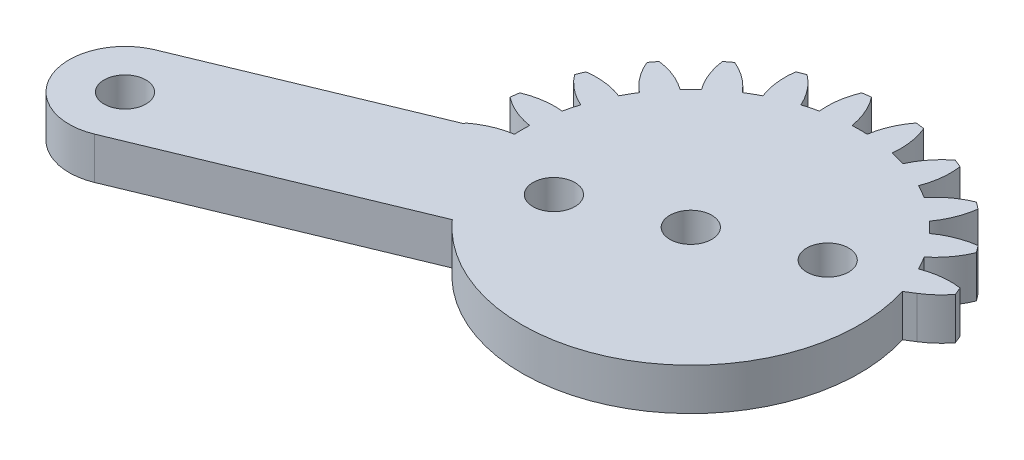
from build123d import *

# Parameters (mm, degrees)
SKETCH1_R           = 1.5
BOSS_EXTRUDE1_DEPTH = 3


with BuildPart() as part:
    # Sketch1 → Boss-Extrude1 (new body)
    with BuildSketch(Plane(origin=(0, 0, 0), x_dir=(1, 0, 0), z_dir=(0, 1, 0))):
        with BuildLine():
            Line((-9.012614242, -8.062715867), (-27.10951678, -15.558698335))
            ThreePointArc((-27.10951678, -15.558698335), (-32.335768639, -13.393913934), (-30.170984238, -8.167662075))
            Line((-30.170984238, -8.167662075), (-14.527279952, -1.687827594))
            ThreePointArc((-14.527279952, -1.687827594), (-14.532365143, -1.643468323), (-14.537314884, -1.599093734))
            ThreePointArc((-14.537314884, -1.599093734), (-13.375367561, -0.916420891), (-12.08056518, -0.542722374))
            ThreePointArc((-12.08056518, -0.542722374), (-12.092750003, -1.6e-08), (-12.080565181, 0.542722343))
            ThreePointArc((-12.080565181, 0.542722343), (-13.375367564, 0.91642086), (-14.537314887, 1.599093703))
            ThreePointArc((-14.537314887, 1.599093703), (-14.499881093, 1.908945545), (-14.455843804, 2.217928021))
            ThreePointArc((-14.455843804, 2.217928021), (-13.156800144, 2.576605254), (-11.80939679, 2.602450787))
            ThreePointArc((-11.80939679, 2.602450787), (-11.680699543, 3.129833994), (-11.528463026, 3.650909874))
            ThreePointArc((-11.528463026, 3.650909874), (-12.682425794, 4.346994439), (-13.628091988, 5.307139865))
            ThreePointArc((-13.628091988, 5.307139865), (-13.511738162, 5.596745183), (-13.389230858, 5.883801647))
            ThreePointArc((-13.389230858, 5.883801647), (-12.041618538, 5.89404001), (-10.733437524, 5.570271228))
            ThreePointArc((-10.733437524, 5.570271228), (-10.472628711, 6.046374991), (-10.190715165, 6.51029393))
            ThreePointArc((-10.190715165, 6.51029393), (-11.125197663, 7.48132753), (-11.790137141, 8.653513216))
            ThreePointArc((-11.790137141, 8.653513216), (-11.602792603, 8.903135886), (-11.410163954, 9.148703915))
            ThreePointArc((-11.410163954, 9.148703915), (-10.105820527, 8.80980568), (-8.926012227, 8.158486891))
            ThreePointArc((-8.926012227, 8.158486891), (-8.550865537, 8.550865523), (-8.158486906, 8.926012214))
            ThreePointArc((-8.158486906, 8.926012214), (-8.809805695, 10.105820514), (-9.148703931, 11.410163942))
            ThreePointArc((-9.148703931, 11.410163942), (-8.903135901, 11.602792591), (-8.653513232, 11.79013713))
            ThreePointArc((-8.653513232, 11.79013713), (-7.481327547, 11.125197652), (-6.510293947, 10.190715155))
            ThreePointArc((-6.510293947, 10.190715155), (-6.046375007, 10.472628701), (-5.570271245, 10.733437515))
            ThreePointArc((-5.570271245, 10.733437515), (-5.894040027, 12.04161853), (-5.883801664, 13.38923085))
            ThreePointArc((-5.883801664, 13.38923085), (-5.5967452, 13.511738155), (-5.307139882, 13.628091982))
            ThreePointArc((-5.307139882, 13.628091982), (-4.346994456, 12.682425788), (-3.650909891, 11.52846302))
            ThreePointArc((-3.650909891, 11.52846302), (-3.129834011, 11.680699538), (-2.602450802, 11.809396786))
            ThreePointArc((-2.602450802, 11.809396786), (-2.57660527, 13.156800141), (-2.217928037, 14.455843802))
            ThreePointArc((-2.217928037, 14.455843802), (-1.908945561, 14.499881091), (-1.599093718, 14.537314885))
            ThreePointArc((-1.599093718, 14.537314885), (-0.916420875, 13.375367563), (-0.542722359, 12.08056518))
            ThreePointArc((-0.542722359, 12.08056518), (2e-09, 12.092750003), (0.542722362, 12.08056518))
            ThreePointArc((0.542722362, 12.08056518), (0.916420879, 13.375367562), (1.599093721, 14.537314885))
            ThreePointArc((1.599093721, 14.537314885), (1.908945564, 14.49988109), (2.21792804, 14.455843801))
            ThreePointArc((2.21792804, 14.455843801), (2.576605273, 13.15680014), (2.602450806, 11.809396786))
            ThreePointArc((2.602450806, 11.809396786), (3.129834014, 11.680699537), (3.650909894, 11.528463019))
            ThreePointArc((3.650909894, 11.528463019), (4.346994459, 12.682425786), (5.307139885, 13.628091981))
            ThreePointArc((5.307139885, 13.628091981), (5.596745203, 13.511738153), (5.883801667, 13.389230849))
            ThreePointArc((5.883801667, 13.389230849), (5.89404003, 12.041618528), (5.570271248, 10.733437514))
            ThreePointArc((5.570271248, 10.733437514), (6.04637501, 10.4726287), (6.510293949, 10.190715153))
            ThreePointArc((6.510293949, 10.190715153), (7.481327549, 11.12519765), (8.653513234, 11.790137128))
            ThreePointArc((8.653513234, 11.790137128), (8.903135904, 11.602792589), (9.148703933, 11.41016394))
            ThreePointArc((9.148703933, 11.41016394), (8.809805697, 10.105820513), (8.158486908, 8.926012212))
            ThreePointArc((8.158486908, 8.926012212), (8.550865539, 8.550865522), (8.926012229, 8.15848689))
            ThreePointArc((8.926012229, 8.15848689), (10.105820529, 8.809805679), (11.410163956, 9.148703914))
            ThreePointArc((11.410163956, 9.148703914), (11.602792604, 8.903135884), (11.790137143, 8.653513214))
            ThreePointArc((11.790137143, 8.653513214), (11.125197664, 7.481327529), (10.190715166, 6.510293928))
            ThreePointArc((10.190715166, 6.510293928), (10.472628712, 6.046374989), (10.733437525, 5.570271227))
            ThreePointArc((10.733437525, 5.570271227), (12.041618538, 5.894040009), (13.389230858, 5.883801646))
            ThreePointArc((13.389230858, 5.883801646), (13.511738162, 5.596745182), (13.628091989, 5.307139864))
            ThreePointArc((13.628091989, 5.307139864), (12.967370885, 4.588201714), (12.187984486, 3.999999979))
            Line((12.187984486, 3.999999979), (11.544422781, 3.600125731))
            ThreePointArc((11.544422781, 3.600125731), (5.967242425, -10.517919019), (-9.012614242, -8.062715867))
        make_face()
        Circle(SKETCH1_R, mode=Mode.SUBTRACT)
        with Locations((-28.640250509, -11.863180205)):
            Circle(SKETCH1_R, mode=Mode.SUBTRACT)
        with Locations((-6.929096489, -2.870125744)):
            Circle(SKETCH1_R, mode=Mode.SUBTRACT)
        with Locations((6.929111486, 2.870131956)):
            Circle(SKETCH1_R, mode=Mode.SUBTRACT)
    extrude(amount=BOSS_EXTRUDE1_DEPTH)


solid = part.part
